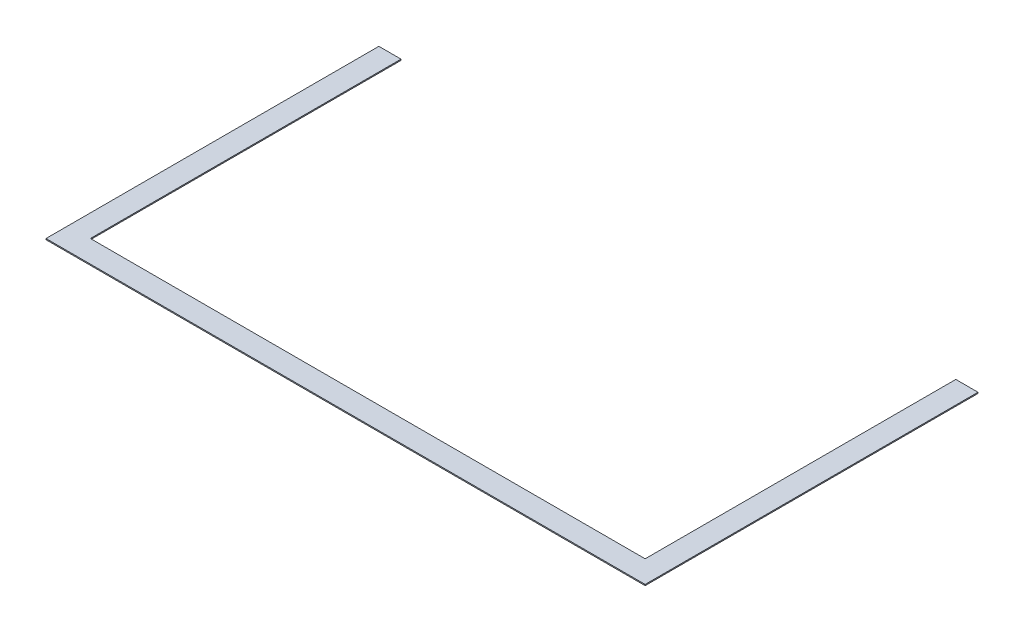
from build123d import *

# Parameters (mm, degrees)
BOSS_EXTRUDE1_DEPTH = 5


with BuildPart() as part:
    # Sketch1 → Boss-Extrude1 (new body)
    with BuildSketch(Plane(origin=(0, 0, 0), x_dir=(1, 0, 0), z_dir=(0, 1, 0))):
        Polygon((-106.62115926, -63.37884074), (2593.37884074, -63.37884074), (2593.37884074, 1436.62115926), (2493.37884074, 1436.62115926), (2493.37884074, 186.62115926), (2493.37884074, 36.62115926), (-6.62115926, 36.62115926), (-6.62115926, 1436.62115926), (-106.62115926, 1436.62115926), align=None)
    extrude(amount=BOSS_EXTRUDE1_DEPTH)


solid = part.part
